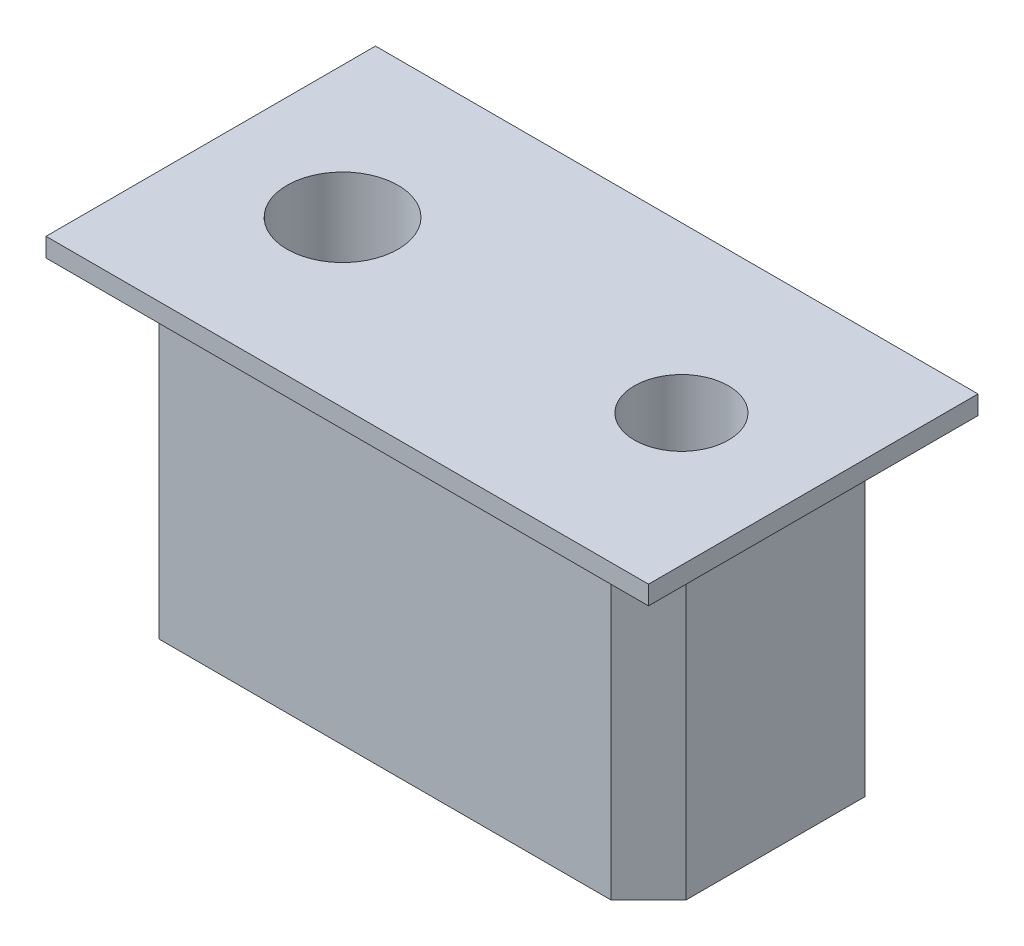
from build123d import *

# Parameters (mm, degrees)
SKETCH1_W      = 14
SKETCH1_H      = 8.2625
EXTRUDE1_DEPTH = 3.375
SKETCH4_W      = 16
SKETCH4_H      = 8.75
EXTRUDE2_DEPTH = 0.5
SKETCH2_W      = 1.4732
SKETCH2_H      = 14.507045303
SKETCH3_W      = 1.25
SKETCH3_H      = 20
CHAMFER1_SIZE  = 1
FILLET1_R      = 0.25


with BuildPart() as part:
    # Sketch1 → Extrude1 (new body, symmetric)
    with BuildSketch(Plane.XY):
        with Locations((0, 189.13125)):
            Rectangle(SKETCH1_W, SKETCH1_H)
    extrude(amount=EXTRUDE1_DEPTH, both=True)

    # Sketch4 → Extrude2 (add)
    with BuildSketch(Plane(origin=(0, 193.2625, 0), x_dir=(1, 0, 0), z_dir=(0, 1, 0))):
        Rectangle(SKETCH4_W, SKETCH4_H)
    extrude(amount=EXTRUDE2_DEPTH)

    # Sketch2 → Cut-Revolve1 (revolve, cut)
    with BuildSketch(Plane(origin=(9.451328919, 219.930638069, 0), x_dir=(1, 0, 0), z_dir=(0, 0, -1)), mode=Mode.PRIVATE) as cut_revolve1_sk:
        with Locations((-13.214728919, 31.182818604)):
            Rectangle(SKETCH2_W, SKETCH2_H)
    revolve(cut_revolve1_sk.sketch.rotate(Axis((-4.5, 202.803113019, 0), (0, -1, 0)), 90), axis=Axis((-4.5, 202.803113019, 0), (0, -1, 0)), mode=Mode.SUBTRACT)  # turned: the seam where the file's is

    # Sketch3 → Cut-Revolve2 (revolve, cut)
    with BuildSketch(Plane.XY, mode=Mode.PRIVATE) as cut_revolve2_sk:
        with Locations((5.125, 186.074655067)):
            Rectangle(SKETCH3_W, SKETCH3_H)
    revolve(cut_revolve2_sk.sketch.rotate(Axis((4.5, 219.496854939, 0), (0, -1, 0)), 90), axis=Axis((4.5, 219.496854939, 0), (0, -1, 0)), mode=Mode.SUBTRACT)  # turned: the seam where the file's is

    # Chamfer1
    chamfer1_edges = [part.edges().sort_by_distance(p)[0] for p in [
        (7, 189.13125, 3.375),
        (-7, 189.13125, 3.375),
        (7, 189.13125, -3.375),
        (-7, 189.13125, -3.375),
    ]]
    chamfer(chamfer1_edges, length=CHAMFER1_SIZE)

    # Fillet1
    fillet1_edges = [part.edges().sort_by_distance(p)[0] for p in [
        (-7, 193.2625, 0),
        (0, 193.2625, -3.375),
        (7, 193.2625, 0),
        (0, 193.2625, 3.375),
        (-6.5, 193.2625, -2.875),
        (6.5, 193.2625, -2.875),
        (6.5, 193.2625, 2.875),
        (-6.5, 193.2625, 2.875),
    ]]
    fillet(fillet1_edges, radius=FILLET1_R)


solid = part.part
